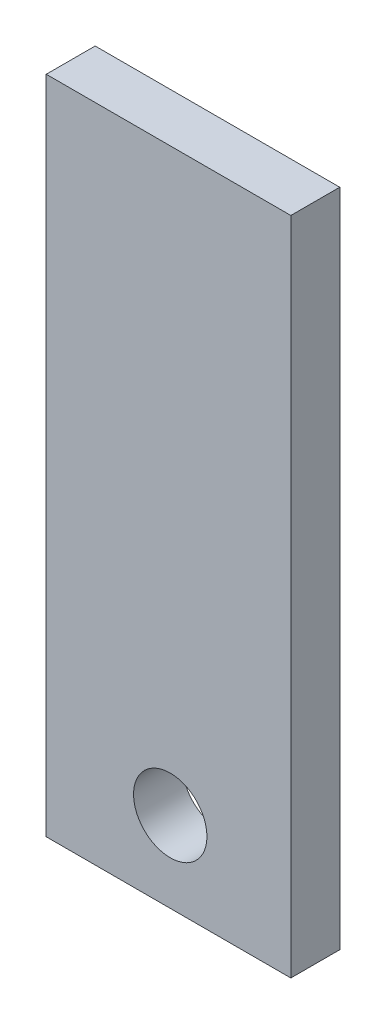
from build123d import *

# Parameters (mm, degrees)
CROQUIS1_W              = 70
CROQUIS1_H              = 189
CROQUIS1_R              = 10.5
SALIENTE_EXTRUIR3_DEPTH = 14


with BuildPart() as part:
    # Croquis1 → Saliente-Extruir3 (new body)
    with BuildSketch(Plane.XY):
        with Locations((35, 94.5)):
            Rectangle(CROQUIS1_W, CROQUIS1_H)
        with Locations((35.49, 23.040561622)):
            Circle(CROQUIS1_R, mode=Mode.SUBTRACT)
    extrude(amount=SALIENTE_EXTRUIR3_DEPTH)


solid = part.part
